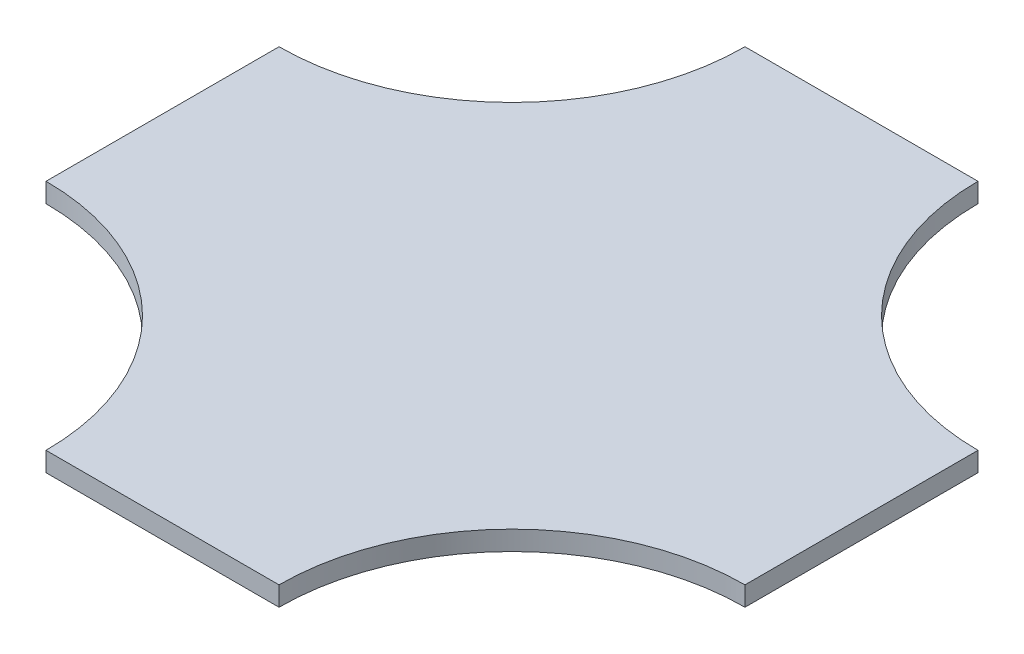
from build123d import *

# Parameters (mm, degrees)
BOSS_EXTRUDE1_DEPTH = 10


with BuildPart() as part:
    # Sketch1 → Boss-Extrude1 (new body)
    with BuildSketch(Plane(origin=(0, 0, 0), x_dir=(1, 0, 0), z_dir=(0, 1, 0))):
        Polygon((60, -60), (60, -180), (-60, -180), (-60, -60), (-180, -60), (-180, 60), (-60, 60), (-60, 180), (60, 180), (60, 60), (180, 60), (180, -60), align=None)
        with BuildLine():
            Line((-60, 180), (-60, 60))
            Line((-60, 60), (-180, 60))
            ThreePointArc((-180, 60), (-95.147186258, 95.147186258), (-60, 180))
        make_face()
        with BuildLine():
            ThreePointArc((60, 180), (95.147186258, 95.147186258), (180, 60))
            Line((180, 60), (60, 60))
            Line((60, 60), (60, 180))
        make_face()
        with BuildLine():
            ThreePointArc((180, -60), (95.147186258, -95.147186258), (60, -180))
            Line((60, -180), (60, -60))
            Line((60, -60), (180, -60))
        make_face()
        with BuildLine():
            Line((-180, -60), (-60, -60))
            Line((-60, -60), (-60, -180))
            ThreePointArc((-60, -180), (-95.147186258, -95.147186258), (-180, -60))
        make_face()
    extrude(amount=BOSS_EXTRUDE1_DEPTH)


solid = part.part
